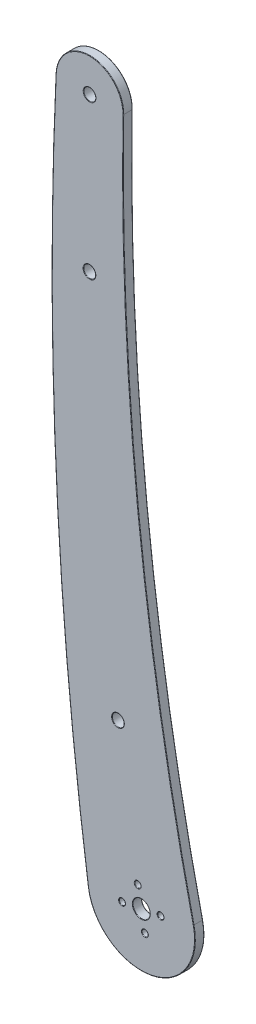
from build123d import *

# Parameters (mm, degrees)
SKETCH1_R           = 2.8
SKETCH1_R_2         = 1.95
SKETCH1_R_3         = 1
BOSS_EXTRUDE1_DEPTH = 3
FILLET1_R           = 0.15


with BuildPart() as part:
    # Sketch1 → Boss-Extrude1 (new body)
    with BuildSketch(Plane.XY):
        with BuildLine():
            ThreePointArc((-26.079167388, 278.756611768), (-21.239110839, 169.437578513), (-3.167903279, 61.513954424))
            ThreePointArc((-3.167903279, 61.513954424), (-17.024180678, 40.374281798), (-37.547403455, 55.128247669))
            ThreePointArc((-37.547403455, 55.128247669), (-48.065680098, 167.044655833), (-48.065582127, 279.454248661))
            ThreePointArc((-48.065582127, 279.454248661), (-36.728796341, 289.933495141), (-26.079167388, 278.756611768))
        make_face()
        with Locations((-20.22, 57.58)):
            Circle(SKETCH1_R, mode=Mode.SUBTRACT)
        with Locations((-37.077654746, 278.93902845)):
            Circle(SKETCH1_R_2, mode=Mode.SUBTRACT)
        with Locations((-37.107397794, 228.939037297)):
            Circle(SKETCH1_R_2, mode=Mode.SUBTRACT)
        with Locations((-27.821012361, 106.998868978)):
            Circle(SKETCH1_R_2, mode=Mode.SUBTRACT)
        with Locations((-19.053069402, 51.297454896)):
            Circle(SKETCH1_R_3, mode=Mode.SUBTRACT)
        with Locations((-26.502545104, 56.413069402)):
            Circle(SKETCH1_R_3, mode=Mode.SUBTRACT)
        with Locations((-21.386930598, 63.862545104)):
            Circle(SKETCH1_R_3, mode=Mode.SUBTRACT)
        with Locations((-13.937454896, 58.746930598)):
            Circle(SKETCH1_R_3, mode=Mode.SUBTRACT)
    extrude(amount=-BOSS_EXTRUDE1_DEPTH)

    # Fillet1
    fillet1_edges = [part.edges().sort_by_distance(p)[0] for p in [
        (-23.02, 57.58, -3),
        (-23.02, 57.58, 0),
        (-17.024180678, 40.374281798, -3),
        (-39.027654746, 278.93902845, -3),
        (-39.027654746, 278.93902845, 0),
        (-21.239110839, 169.437578513, -3),
        (-29.771012361, 106.998868978, -3),
        (-29.771012361, 106.998868978, 0),
        (-39.057397794, 228.939037297, -3),
        (-39.057397794, 228.939037297, 0),
        (-20.053069402, 51.297454896, -3),
        (-20.053069402, 51.297454896, 0),
        (-27.502545104, 56.413069402, -3),
        (-27.502545104, 56.413069402, 0),
        (-22.386930598, 63.862545104, -3),
        (-22.386930598, 63.862545104, 0),
        (-14.937454896, 58.746930598, -3),
        (-14.937454896, 58.746930598, 0),
        (-36.728796341, 289.933495141, -3),
        (-21.239110839, 169.437578513, 0),
        (-17.024180678, 40.374281798, 0),
        (-48.065680098, 167.044655833, 0),
        (-36.728796341, 289.933495141, 0),
        (-48.065680098, 167.044655833, -3),
    ]]
    fillet(fillet1_edges, radius=FILLET1_R)


solid = part.part
